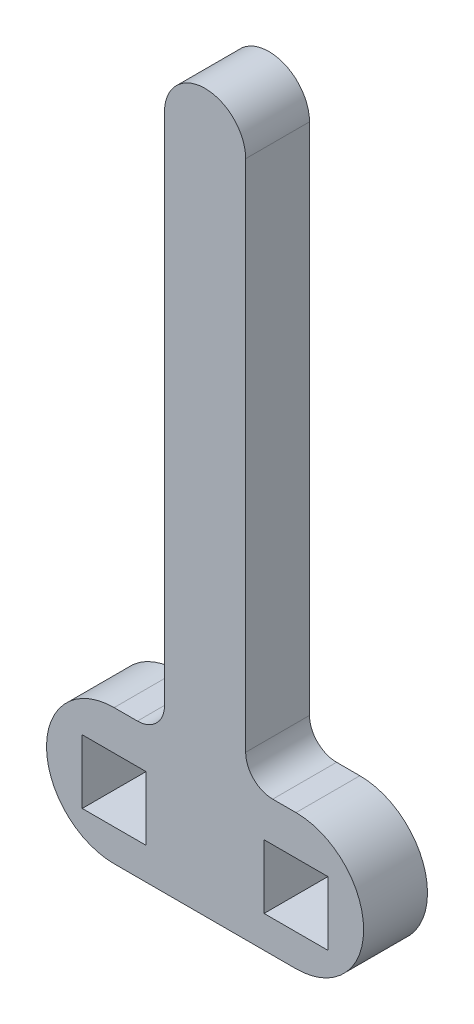
from build123d import *

# Parameters (mm, degrees)
SKETCH1_W           = 5.9944
SKETCH1_H           = 5.9944
BOSS_EXTRUDE1_DEPTH = 5.9944


with BuildPart() as part:
    # Sketch1 → Boss-Extrude1 (new body)
    with BuildSketch(Plane.XY):
        with BuildLine():
            Line((384.610540851, 111.993994152), (367.537765391, 111.993994152))
            ThreePointArc((367.537765391, 111.993994152), (361.187765391, 118.343994152), (367.537765391, 124.693994152))
            Line((367.537765391, 124.693994152), (369.724153121, 124.693994152))
            ThreePointArc((369.724153121, 124.693994152), (371.520204345, 125.437942928), (372.264153121, 127.233994152))
            Line((372.264153121, 127.233994152), (372.264153121, 175.493994152))
            ThreePointArc((372.264153121, 175.493994152), (376.074153121, 179.303994152), (379.884153121, 175.493994152))
            Line((379.884153121, 175.493994152), (379.884153121, 127.233994152))
            ThreePointArc((379.884153121, 127.233994152), (380.628101897, 125.437942928), (382.424153121, 124.693994152))
            Line((382.424153121, 124.693994152), (384.610540851, 124.693994152))
            ThreePointArc((384.610540851, 124.693994152), (390.960540851, 118.343994152), (384.610540851, 111.993994152))
        make_face()
        with Locations((384.610540851, 117.991248441)):
            Rectangle(SKETCH1_W, SKETCH1_H, mode=Mode.SUBTRACT)
        with Locations((367.537765391, 117.991248441)):
            Rectangle(SKETCH1_W, SKETCH1_H, mode=Mode.SUBTRACT)
    extrude(amount=BOSS_EXTRUDE1_DEPTH)


solid = part.part
